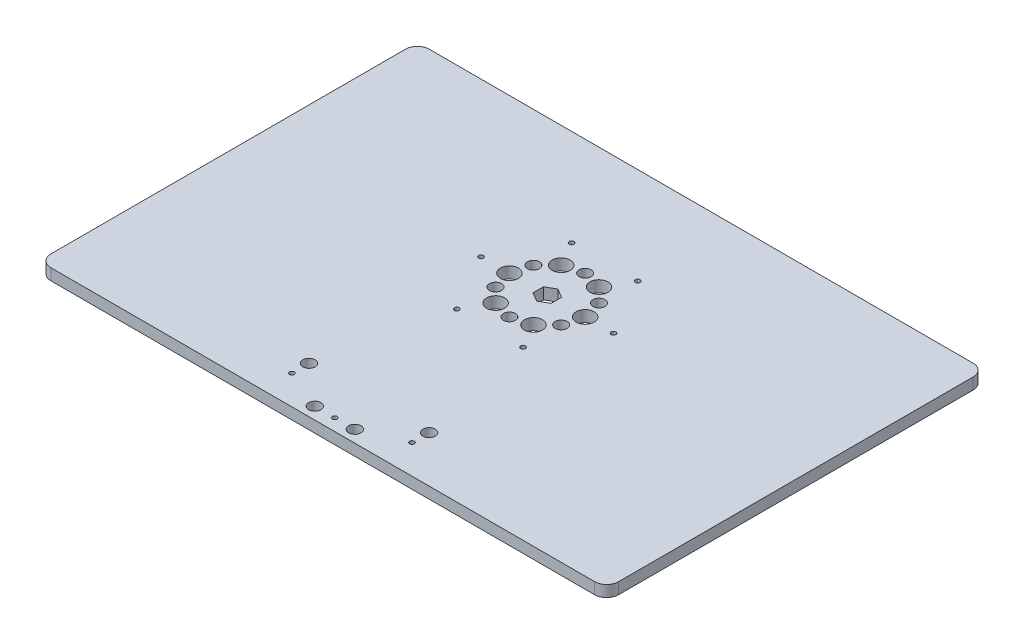
from build123d import *

# Parameters (mm, degrees)
SKETCH1_W            = 300
SKETCH1_H            = 200
BOSS_EXTRUDE1_DEPTH  = 6
SKETCH6_R            = 2.5
CUT_EXTRUDE2_DEPTH   = 7
FILLET1_R            = 6.35
SKETCH16_R           = 3.25
M5_TAP2_DEPTH        = 7
SKETCH17_R           = 1.25
SKETCH17_R_2         = 3.175
SKETCH17_R_3         = 4.7625
M3_COUNTERBORE_DEPTH = 7
CUT_EXTRUDE6_DEPTH   = 7
SKETCH19_R           = 1.25
CUT_EXTRUDE7_DEPTH   = 7


with BuildPart() as part:
    # Sketch1 → Boss-Extrude1 (new body)
    with BuildSketch(Plane(origin=(0, 0, 0), x_dir=(1, 0, 0), z_dir=(0, 1, 0))):
        with Locations((150, 100)):
            Rectangle(SKETCH1_W, SKETCH1_H)
    extrude(amount=BOSS_EXTRUDE1_DEPTH)

    # Sketch6 → Cut-Extrude2 (cut, through all)
    with BuildSketch(Plane(origin=(0, 6, 0), x_dir=(1, 0, 0), z_dir=(0, 1, 0))):
        with Locations((150, 118.65102)):
            Circle(SKETCH6_R)
    extrude(amount=-CUT_EXTRUDE2_DEPTH, mode=Mode.SUBTRACT)

    # Fillet1
    fillet1_edges = [part.edges().sort_by_distance(p)[0] for p in [
        (0, 3, -200),
        (300, 3, -200),
        (300, 3, 0),
        (0, 3, 0),
    ]]
    fillet(fillet1_edges, radius=FILLET1_R)

    # Sketch16 → M5-tap2 (cut, through all)
    with BuildSketch(Plane(origin=(0, 6, -5.8), x_dir=(1, 0, 0), z_dir=(0, -1, 0))):
        with Locations((118.25, -18.65102)):
            Circle(SKETCH16_R)
        with Locations((139.416666667, -0.55098)):
            Circle(SKETCH16_R)
        with Locations((160.583333333, -0.55098)):
            Circle(SKETCH16_R)
        with Locations((181.75, -18.65102)):
            Circle(SKETCH16_R)
    extrude(amount=M5_TAP2_DEPTH, mode=Mode.SUBTRACT)

    # Sketch17 → M3_counterbore (cut, through all)
    with BuildSketch(Plane(origin=(0, 6, 0), x_dir=(1, 0, 0), z_dir=(0, 1, 0))):
        with Locations((185, 118.65102)):
            Circle(SKETCH17_R)
        with Locations((167.5, 88.340130868)):
            Circle(SKETCH17_R)
        with Locations((132.5, 88.340130868)):
            Circle(SKETCH17_R)
        with Locations((115, 118.65102)):
            Circle(SKETCH17_R)
        with Locations((132.5, 148.961909132)):
            Circle(SKETCH17_R)
        with Locations((167.5, 148.961909132)):
            Circle(SKETCH17_R)
        with Locations((150, 138.65102)):
            Circle(SKETCH17_R_2)
        with Locations((167.320508076, 128.65102)):
            Circle(SKETCH17_R_2)
        with Locations((167.320508076, 108.65102)):
            Circle(SKETCH17_R_2)
        with Locations((150, 98.65102)):
            Circle(SKETCH17_R_2)
        with Locations((132.679491924, 108.65102)):
            Circle(SKETCH17_R_2)
        with Locations((132.679491924, 128.65102)):
            Circle(SKETCH17_R_2)
        with Locations((160, 135.971528076)):
            Circle(SKETCH17_R_3)
        with Locations((170, 118.65102)):
            Circle(SKETCH17_R_3)
        with Locations((160, 101.330511924)):
            Circle(SKETCH17_R_3)
        with Locations((140, 101.330511924)):
            Circle(SKETCH17_R_3)
        with Locations((130, 118.65102)):
            Circle(SKETCH17_R_3)
        with Locations((140, 135.971528076)):
            Circle(SKETCH17_R_3)
    extrude(amount=-M3_COUNTERBORE_DEPTH, mode=Mode.SUBTRACT)

    # Sketch18 → Cut-Extrude6 (cut, through all)
    with BuildSketch(Plane(origin=(0, 6, 0), x_dir=(1, 0, 0), z_dir=(0, 1, 0))):
        Polygon((154.8, 121.422301292), (154.8, 115.879738708), (150, 113.108457416), (145.2, 115.879738708), (145.2, 121.422301292), (150, 124.193582584), align=None)
    extrude(amount=-CUT_EXTRUDE6_DEPTH, mode=Mode.SUBTRACT)

    # Sketch19 → Cut-Extrude7 (cut, through all)
    with BuildSketch(Plane(origin=(0, 6, 0), x_dir=(1, 0, 0), z_dir=(0, 1, 0))):
        with Locations((118.25, 15.401)):
            Circle(SKETCH19_R)
        with Locations((150, 6.35098)):
            Circle(SKETCH19_R)
        with Locations((181.75, 15.401)):
            Circle(SKETCH19_R)
    extrude(amount=-CUT_EXTRUDE7_DEPTH, mode=Mode.SUBTRACT)


solid = part.part
